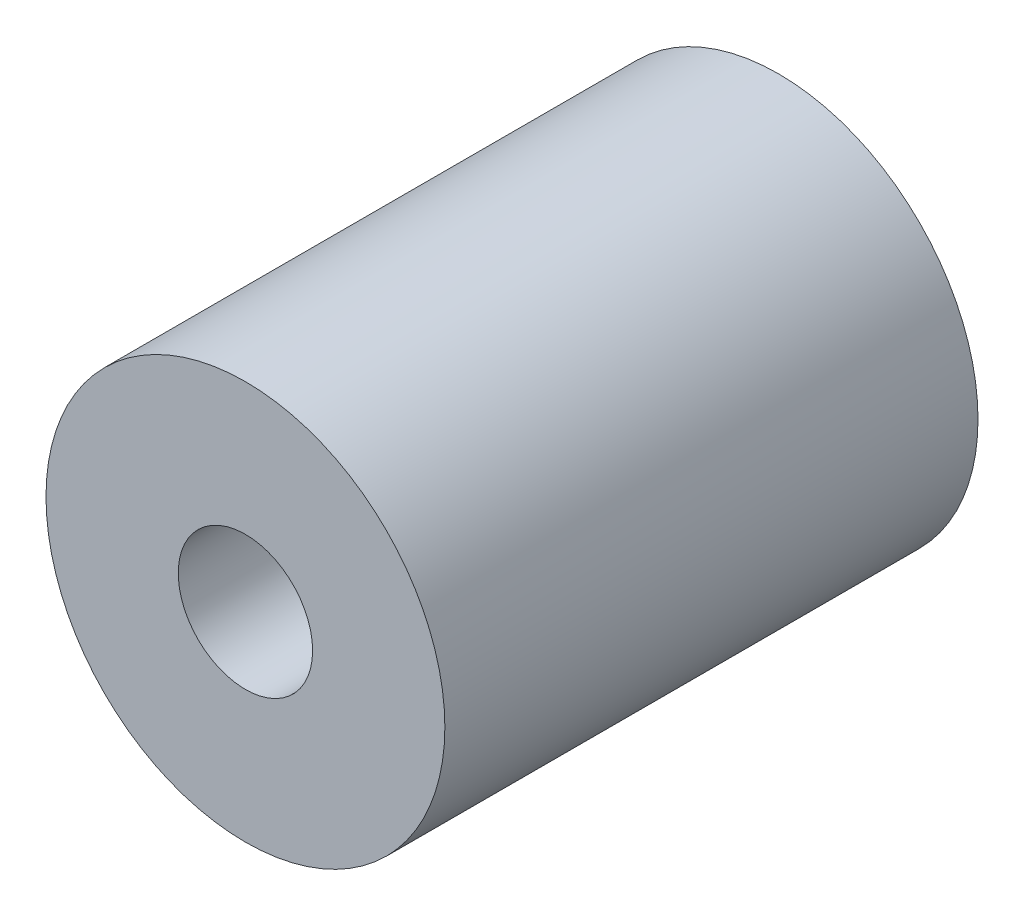
from build123d import *

# Parameters (mm, degrees)
SKETCH1_R           = 15.08125
SKETCH1_R_2         = 5.08
BOSS_EXTRUDE1_DEPTH = 40.31615


with BuildPart() as part:
    # Sketch1 → Boss-Extrude1 (new body)
    with BuildSketch(Plane.XY):
        Circle(SKETCH1_R)
        Circle(SKETCH1_R_2, mode=Mode.SUBTRACT)
    extrude(amount=BOSS_EXTRUDE1_DEPTH)


solid = part.part
